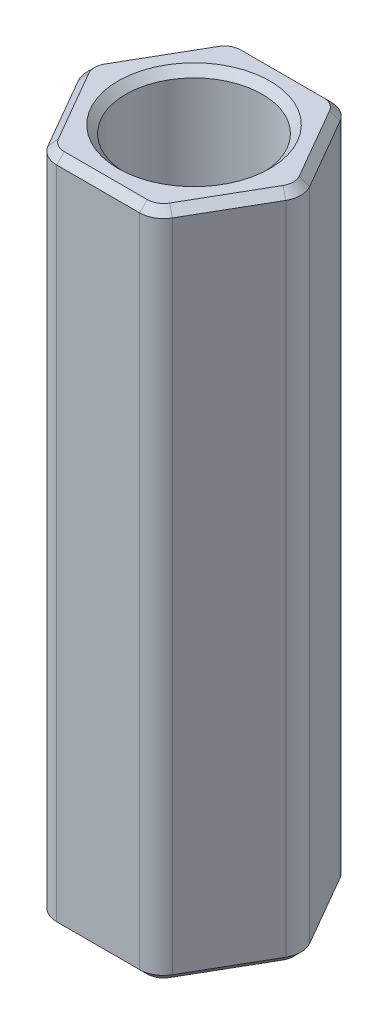
from build123d import *

# Parameters (mm, degrees)
BOSS_EXTRUDE1_DEPTH   = 5.55625
F_4_40_TAPPED_HOLE1_D = 2.2606
FILLET1_R             = 0.396875
CHAMFER1_SIZE         = 0.127


with BuildPart() as part:
    # Sketch1 → Boss-Extrude1 (new body, symmetric)
    with BuildSketch(Plane(origin=(0, 0, 0), x_dir=(1, 0, 0), z_dir=(0, 1, 0))):
        Polygon((0.916543552, 1.5875), (-0.916543552, 1.5875), (-1.833087105, 0), (-0.916543552, -1.5875), (0.916543552, -1.5875), (1.833087105, 0), align=None)
    extrude(amount=BOSS_EXTRUDE1_DEPTH, both=True)

    # #4-40 Tapped Hole1 (through all)
    with Locations(Plane(origin=(0, 5.55625, 0), x_dir=(1, 0, 0), z_dir=(0, 1, 0))):
        with Locations((0, 0)):
            Hole(F_4_40_TAPPED_HOLE1_D / 2)

    # Fillet1
    fillet1_edges = [part.edges().sort_by_distance(p)[0] for p in [
        (1.833087105, 0, 0),
        (0.916543552, 0, 1.5875),
        (-0.916543552, 0, 1.5875),
        (-1.833087105, 0, 0),
        (-0.916543552, 0, -1.5875),
        (0.916543552, 0, -1.5875),
    ]]
    fillet(fillet1_edges, radius=FILLET1_R)

    # Chamfer1
    chamfer1_edges = [part.edges().sort_by_distance(p)[0] for p in [
        (1.1303, 5.55625, 0),
        (1.1303, -5.55625, 0),
        (-1.374815329, -5.55625, -0.79375),
        (-1.374815329, 5.55625, -0.79375),
        (1.374815329, -5.55625, -0.79375),
        (1.374815329, -5.55625, 0.79375),
        (0, -5.55625, 1.5875),
        (-1.374815329, -5.55625, 0.79375),
        (0, -5.55625, -1.5875),
        (-1.771690329, -5.55625, 0),
        (-0.885845164, -5.55625, 1.534328832),
        (0.885845164, -5.55625, 1.534328832),
        (1.771690329, -5.55625, 0),
        (0.885845164, -5.55625, -1.534328832),
        (-0.885845164, -5.55625, -1.534328832),
        (0, 5.55625, -1.5875),
        (1.374815329, 5.55625, -0.79375),
        (-1.374815329, 5.55625, 0.79375),
        (0, 5.55625, 1.5875),
        (1.374815329, 5.55625, 0.79375),
        (-1.771690329, 5.55625, 0),
        (-0.885845164, 5.55625, 1.534328832),
        (0.885845164, 5.55625, 1.534328832),
        (1.771690329, 5.55625, 0),
        (0.885845164, 5.55625, -1.534328832),
        (-0.885845164, 5.55625, -1.534328832),
    ]]
    chamfer(chamfer1_edges, length=CHAMFER1_SIZE)


solid = part.part
